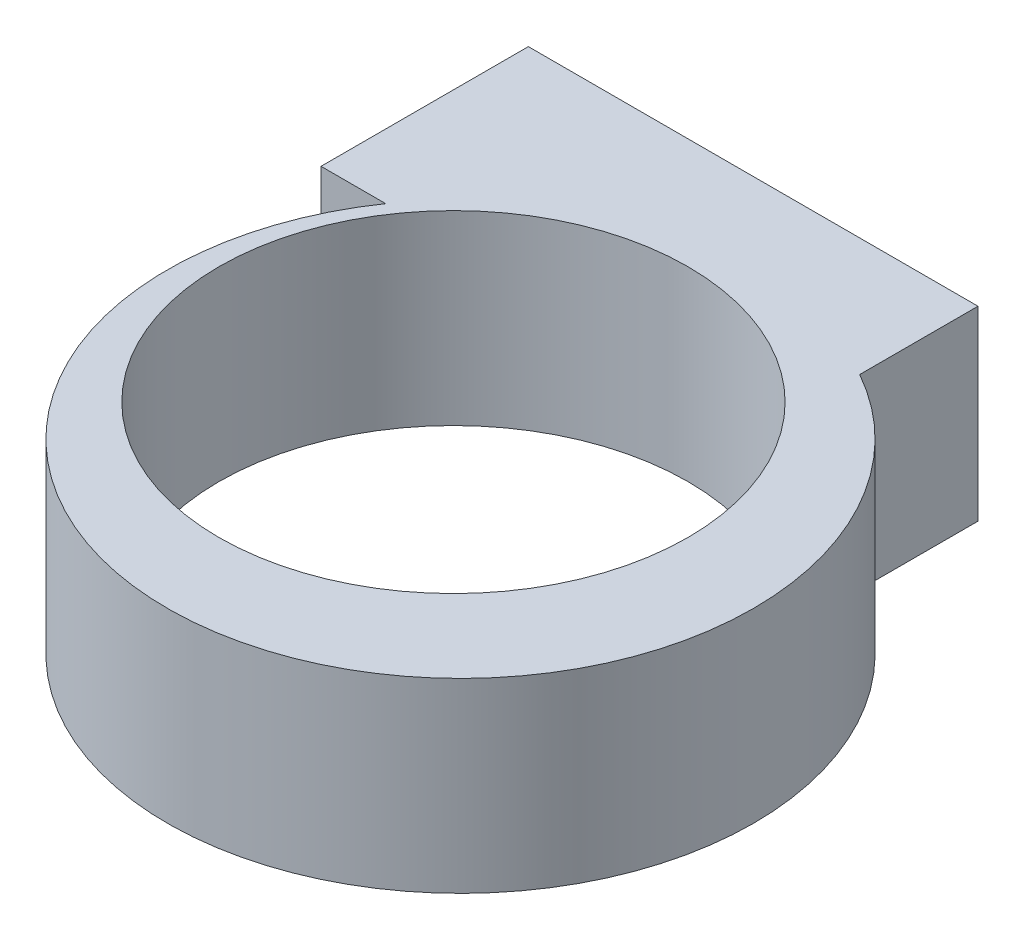
from build123d import *

# Parameters (mm, degrees)
SKETCH1_R                = 5
BOSS_EXTRUDE1_DEPTH      = 3.175
SKETCH2_W                = 7.669126603
SKETCH2_H                = 3.535914735
BOSS_EXTRUDE2_DEPTH      = 3.175
F_8_0_8_DIAMETER_HOLE1_D = 8


with BuildPart() as part:
    # Sketch1 → Boss-Extrude1 (new body)
    with BuildSketch(Plane(origin=(0, 0, 0), x_dir=(1, 0, 0), z_dir=(0, 1, 0))):
        Circle(SKETCH1_R)
    extrude(amount=BOSS_EXTRUDE1_DEPTH)

    # Sketch2 → Boss-Extrude2 (add)
    with BuildSketch(Plane(origin=(0, 3.175, 0), x_dir=(1, 0, 0), z_dir=(0, 1, 0))):
        with Locations((-1.383775104, 4.607725038)):
            Rectangle(SKETCH2_W, SKETCH2_H)
    extrude(amount=-BOSS_EXTRUDE2_DEPTH)

    # Ø8.0 (8) Diameter Hole1 (through all)
    with Locations(Plane(origin=(0, 3.175, 0), x_dir=(1, 0, 0), z_dir=(0, 1, 0))):
        with Locations((-0.606472724, 0.48661405)):
            Hole(F_8_0_8_DIAMETER_HOLE1_D / 2)


solid = part.part
